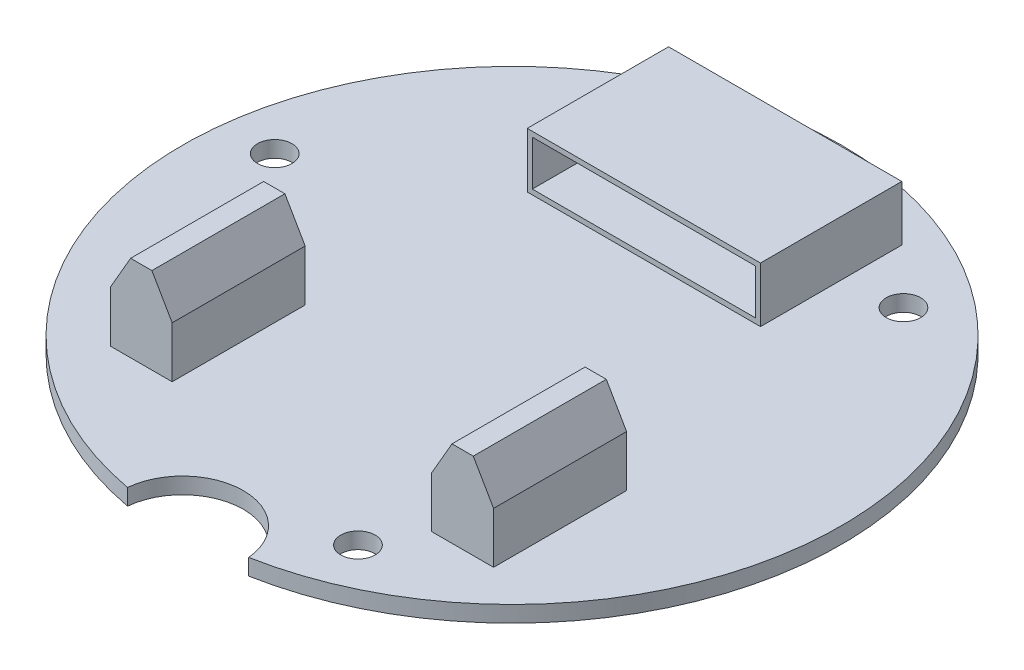
from build123d import *

# Parameters (mm, degrees)
BOSS_EXTRUDE2_DEPTH       = 1.6
SKETCH3_R                 = 1.7
CUT_EXTRUDE1_DEPTH        = 2.6
CIRPATTERN1_COUNT         = 3
SKETCH4_W                 = 13.934293336
SKETCH4_H                 = 5.4356
BOSS_EXTRUDE3_DEPTH       = 11.5
SKETCH5_W                 = 6.096
SKETCH5_H                 = 8.5
BOSS_EXTRUDE4_DEPTH       = 13.1191
CHAMFER1_SIZE             = 2
CHAMFER1_SIZE2            = 3.464101615
CHAMFER1_OF_MIRROR1_SIZE2 = 2
CHAMFER1_OF_MIRROR1_SIZE  = 3.464101615
SKETCH6_W                 = 22
SKETCH6_H                 = 4.4356
CUT_EXTRUDE2_DEPTH        = 13.434293
SKETCH8_W                 = 6.096
SKETCH8_H                 = 13.1191
BOSS_EXTRUDE5_DEPTH       = 2


with BuildPart() as part:
    # Sketch2 → Boss-Extrude2 (new body)
    with BuildSketch(Plane(origin=(0, 0, 0), x_dir=(1, 0, 0), z_dir=(0, 1, 0))):
        with BuildLine():
            ThreePointArc((5.974383185, -31.946153846), (0, 32.5), (-5.974383185, -31.946153846))
            ThreePointArc((-5.974383185, -31.946153846), (0, -26.5), (5.974383185, -31.946153846))
        make_face()
    extrude(amount=BOSS_EXTRUDE2_DEPTH)

    # Sketch3 → Cut-Extrude1 (cut, through all)
    with BuildSketch(Plane(origin=(0, 1.6, 0), x_dir=(1, 0, 0), z_dir=(0, 1, 0))):
        with Locations((10.301681319, -25.497556001)):
            Circle(SKETCH3_R)
    cut_extrude1 = extrude(amount=-CUT_EXTRUDE1_DEPTH, mode=Mode.SUBTRACT)

    # CirPattern1: Cut-Extrude1 ×3 about axis
    cirpattern1_axis = Axis((0, 0, 0), (0, 1, 0))
    for i in range(1, CIRPATTERN1_COUNT):
        add(cut_extrude1.rotate(cirpattern1_axis, i * 360 / CIRPATTERN1_COUNT), mode=Mode.SUBTRACT)

    # Sketch4 → Boss-Extrude3 (add, symmetric)
    with BuildSketch(Plane(origin=(0, 0, 0), x_dir=(0, 0, -1), z_dir=(1, 0, 0))):
        with Locations((19.967146668, 4.3178)):
            Rectangle(SKETCH4_W, SKETCH4_H)
    extrude(amount=BOSS_EXTRUDE3_DEPTH, both=True)

    # Sketch5 → Boss-Extrude4 (add)
    with BuildSketch(Plane.XY.offset(7.6)):
        with Locations((15.848, 5.85)):
            Rectangle(SKETCH5_W, SKETCH5_H)
    boss_extrude4 = extrude(amount=BOSS_EXTRUDE4_DEPTH)

    # Chamfer1
    chamfer1_edges = [part.edges().sort_by_distance(p)[0] for p in [
        (12.8, 10.1, 14.15955),
        (18.896, 10.1, 14.15955),
    ]]
    chamfer1_side = [part.faces().sort_by_distance(p)[0] for p in [
        (15.848, 10.1, 14.15955),
    ]]
    chamfer(chamfer1_edges, length=CHAMFER1_SIZE, length2=CHAMFER1_SIZE2, reference=chamfer1_side[0])

    # Mirror1: Boss-Extrude4 across plane
    add(boss_extrude4.mirror(Plane(origin=(0, 0, 0), x_dir=(0, 0, 1), z_dir=(1, 0, 0))))

    # Chamfer1 of Mirror1
    chamfer1_of_mirror1_edges = [part.edges().sort_by_distance(p)[0] for p in [
        (-12.8, 10.1, 14.15955),
        (-18.896, 10.1, 14.15955),
    ]]
    chamfer(chamfer1_of_mirror1_edges, length=CHAMFER1_OF_MIRROR1_SIZE, length2=CHAMFER1_OF_MIRROR1_SIZE2)

    # Sketch6 → Cut-Extrude2 (cut)
    with BuildSketch(Plane.XY.offset(-13)):
        with Locations((0, 4.3178)):
            Rectangle(SKETCH6_W, SKETCH6_H)
    extrude(amount=-CUT_EXTRUDE2_DEPTH, mode=Mode.SUBTRACT)

    # Sketch8 → Boss-Extrude5 (add)
    with BuildSketch(Plane.XZ):
        with Locations((15.848, 14.15955)):
            Rectangle(SKETCH8_W, SKETCH8_H)
        with Locations((-15.848, 14.15955)):
            Rectangle(SKETCH8_W, SKETCH8_H)
    extrude(amount=BOSS_EXTRUDE5_DEPTH)


solid = part.part
